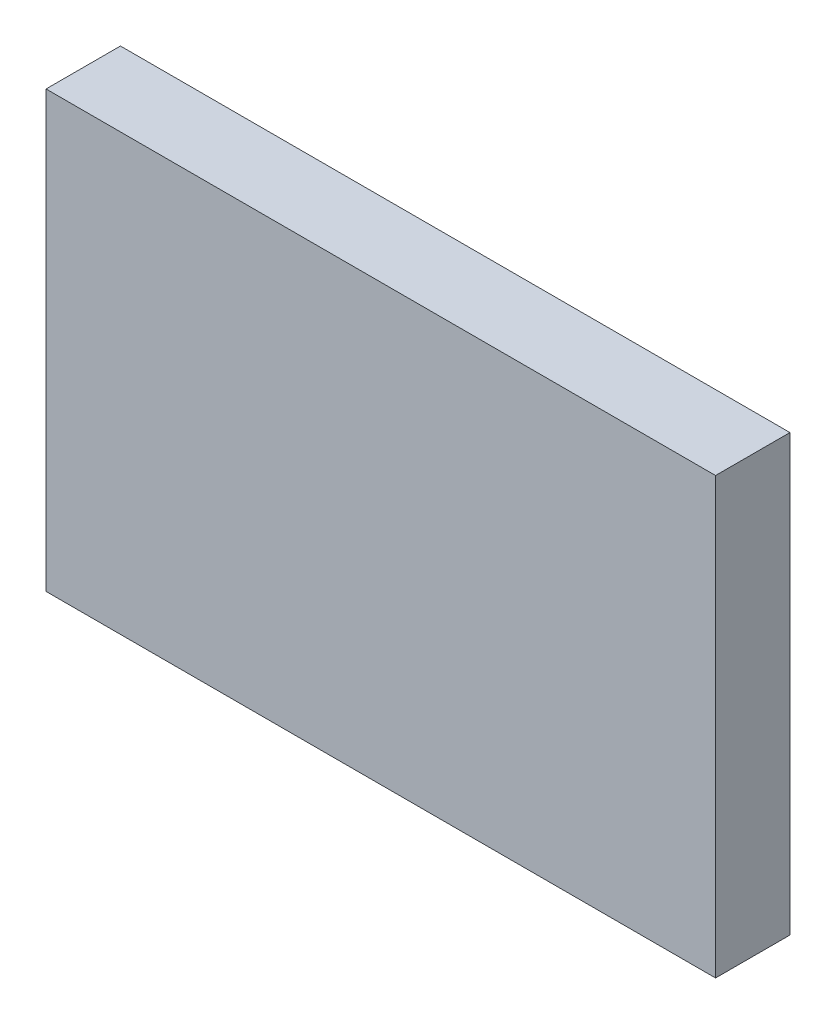
from build123d import *

# Parameters (mm, degrees)
SKETCH1_W           = 45.72
SKETCH1_H           = 29.718
BOSS_EXTRUDE1_DEPTH = 5.08


with BuildPart() as part:
    # Sketch1 → Boss-Extrude1 (new body)
    with BuildSketch(Plane.XY):
        Rectangle(SKETCH1_W, SKETCH1_H)
    extrude(amount=BOSS_EXTRUDE1_DEPTH)


solid = part.part
